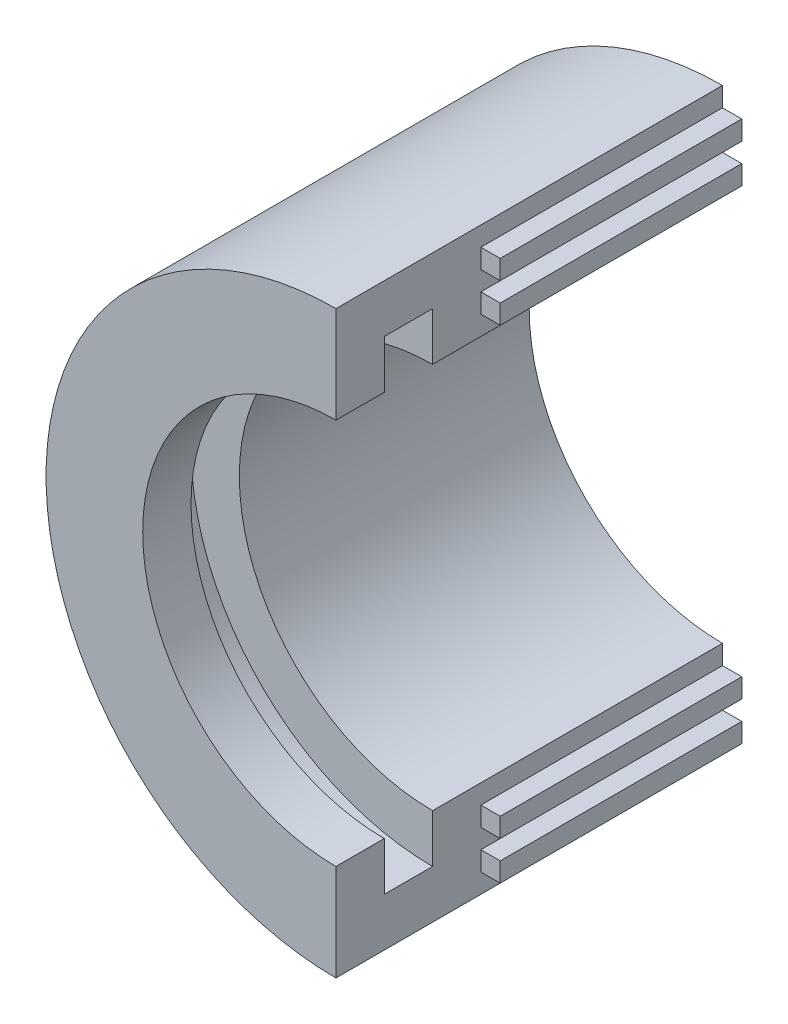
from build123d import *

# Parameters (mm, degrees)
SKETCH1_R               = 76.2
BOSS_EXTRUDE1_DEPTH     = 101.6
SKETCH2_R               = 63.5
CUT_EXTRUDE1_DEPTH      = 25.4
SKETCH3_R               = 63.5
SKETCH3_R_2             = 50.8
BOSS_EXTRUDE2_DEPTH     = 12.7
SKETCH4_R               = 50.8
CUT_EXTRUDE2_DEPTH      = 102.6
CUT_EXTRUDE3_DEPTH      = 102.6
SKETCH6_W               = 63.5
SKETCH6_H               = 5.08
BOSS_EXTRUDE4_DEPTH     = 5.08
LPATTERN1_COUNT         = 2
LPATTERN1_PITCH         = 10.16
MIRROR1_COPY_1_SKETCH_W = 63.5
MIRROR1_COPY_1_SKETCH_H = 5.08
MIRROR1_COPY_1_DEPTH    = 5.08


with BuildPart() as part:
    # Sketch1 → Boss-Extrude1 (new body)
    with BuildSketch(Plane.XY):
        Circle(SKETCH1_R)
    extrude(amount=BOSS_EXTRUDE1_DEPTH)

    # Sketch2 → Cut-Extrude1 (cut)
    with BuildSketch(Plane.XY.offset(101.6)):
        Circle(SKETCH2_R)
    extrude(amount=-CUT_EXTRUDE1_DEPTH, mode=Mode.SUBTRACT)

    # Sketch3 → Boss-Extrude2 (add)
    with BuildSketch(Plane.XY.offset(101.6)):
        Circle(SKETCH3_R)
        Circle(SKETCH3_R_2, mode=Mode.SUBTRACT)
    extrude(amount=-BOSS_EXTRUDE2_DEPTH)

    # Sketch4 → Cut-Extrude2 (cut, through all)
    with BuildSketch(Plane(origin=(0, 0, 0), x_dir=(-1, 0, 0), z_dir=(0, 0, -1))):
        Circle(SKETCH4_R)
    extrude(amount=-CUT_EXTRUDE2_DEPTH, mode=Mode.SUBTRACT)

    # Sketch5 → Cut-Extrude3 (cut, through all)
    with BuildSketch(Plane.XY.offset(101.6)):
        with BuildLine():
            Line((0, 76.2), (0, -76.2))
            ThreePointArc((0, -76.2), (76.2, 0), (0, 76.2))
        make_face()
    extrude(amount=-CUT_EXTRUDE3_DEPTH, mode=Mode.SUBTRACT)

    # Sketch6 → Boss-Extrude4 (add)
    with BuildSketch(Plane(origin=(0, 0, 0), x_dir=(0, 0, -1), z_dir=(1, 0, 0))):
        with Locations((-31.75, -58.42)):
            Rectangle(SKETCH6_W, SKETCH6_H)
    boss_extrude4 = extrude(amount=BOSS_EXTRUDE4_DEPTH)

    # LPattern1: Boss-Extrude4 ×2
    with Locations(*[(0, -i * LPATTERN1_PITCH, 0) for i in range(1, LPATTERN1_COUNT)]):
        add(boss_extrude4)

    # Mirror1: Boss-Extrude4 across plane
    add(boss_extrude4.mirror(Plane.ZX))

    # Mirror1 copy 1 sketch → Mirror1 copy 1 (add)
    with BuildSketch(Plane(origin=(0, 10.16, 0), x_dir=(0, 0, -1), z_dir=(1, 0, 0))):
        with Locations((-31.75, 58.42)):
            Rectangle(MIRROR1_COPY_1_SKETCH_W, MIRROR1_COPY_1_SKETCH_H)
    extrude(amount=MIRROR1_COPY_1_DEPTH)


solid = part.part
